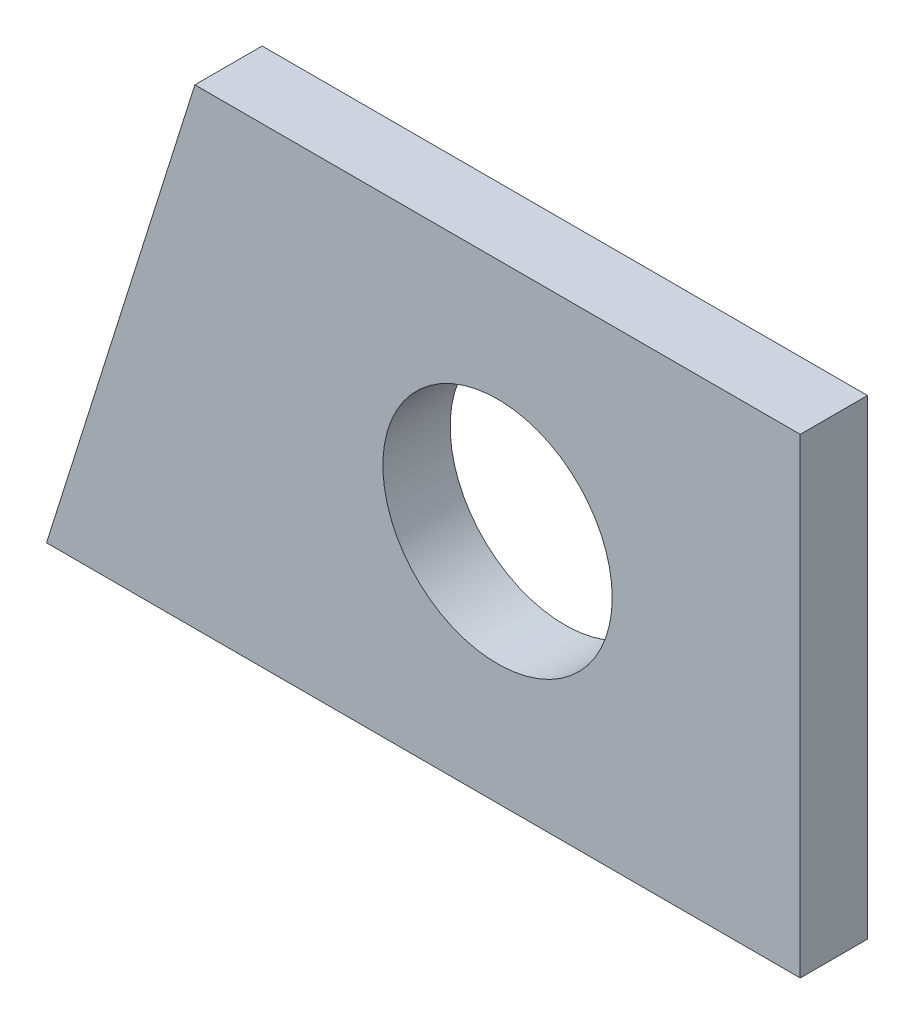
from build123d import *

# Parameters (mm, degrees)
SKETCH1_R           = 1.705
BOSS_EXTRUDE1_DEPTH = 1


with BuildPart() as part:
    # Sketch1 → Boss-Extrude1 (new body)
    with BuildSketch(Plane.XY):
        Polygon((-3.397125795, 3.5), (-5.602874205, -3.5), (5.602874205, -3.5), (5.602874205, 3.5), align=None)
        with Locations((1.102874205, 0)):
            Circle(SKETCH1_R, mode=Mode.SUBTRACT)
    extrude(amount=BOSS_EXTRUDE1_DEPTH)


solid = part.part
